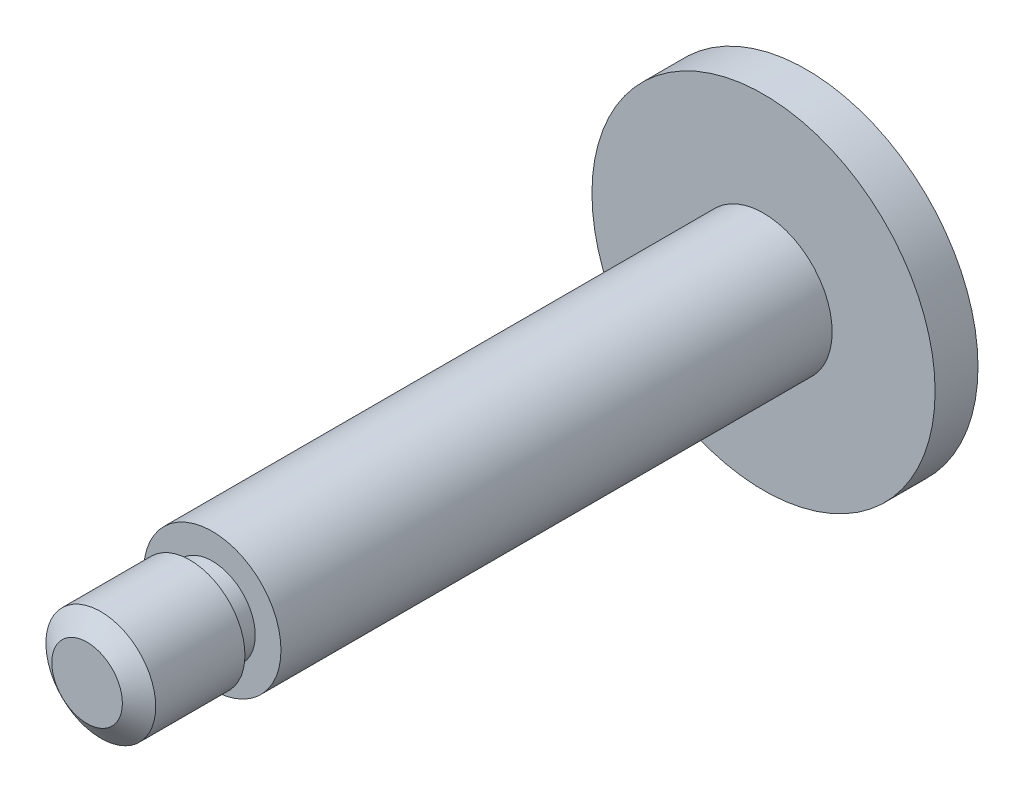
from build123d import *

# Parameters (mm, degrees)
ESQUISSE1_R        = 20
BOSS_EXTRU_1_DEPTH = 5
ESQUISSE2_R        = 8
BOSS_EXTRU_2_DEPTH = 64.25
ESQUISSE3_R        = 5
BOSS_EXTRU_3_DEPTH = 2.6
ESQUISSE4_R        = 6.4
BOSS_EXTRU_4_DEPTH = 12
CHANFREIN1_SIZE    = 1.6
CHANFREIN1_SIZE2   = 2.285036811


with BuildPart() as part:
    # Esquisse1 → Boss.-Extru.1 (new body)
    with BuildSketch(Plane.XY):
        Circle(ESQUISSE1_R)
    extrude(amount=BOSS_EXTRU_1_DEPTH)

    # Esquisse2 → Boss.-Extru.2 (add)
    with BuildSketch(Plane.XY.offset(5)):
        Circle(ESQUISSE2_R)
    extrude(amount=BOSS_EXTRU_2_DEPTH)

    # Esquisse3 → Boss.-Extru.3 (add)
    with BuildSketch(Plane.XY.offset(69.25)):
        Circle(ESQUISSE3_R)
    extrude(amount=BOSS_EXTRU_3_DEPTH)

    # Esquisse4 → Boss.-Extru.4 (add)
    with BuildSketch(Plane.XY.offset(71.85)):
        Circle(ESQUISSE4_R)
    extrude(amount=BOSS_EXTRU_4_DEPTH)

    # Chanfrein1
    chanfrein1_edges = [part.edges().sort_by_distance(p)[0] for p in [
        (-6.4, 0, 83.85),
    ]]
    chanfrein1_side = [part.faces().sort_by_distance(p)[0] for p in [
        (-6.4, 0, 77.85),
    ]]
    chamfer(chanfrein1_edges, length=CHANFREIN1_SIZE, length2=CHANFREIN1_SIZE2, reference=chanfrein1_side[0])


solid = part.part
